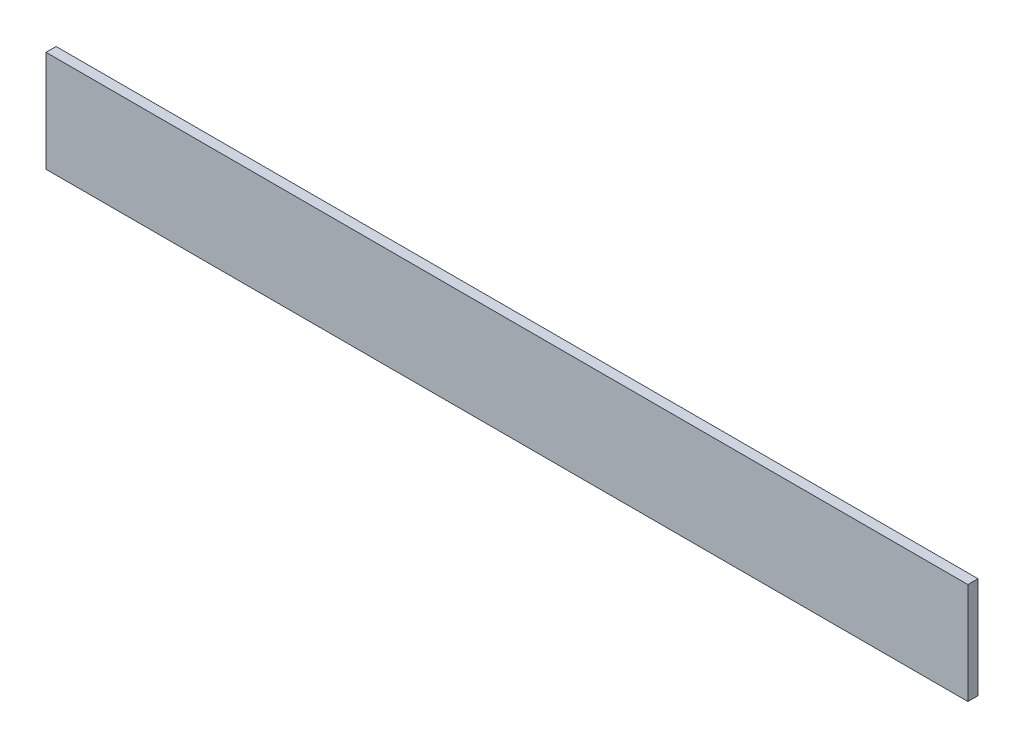
from build123d import *

# Parameters (mm, degrees)
ESQUISSE1_W        = 273
ESQUISSE1_H        = 30
BOSS_EXTRU_1_DEPTH = 3


with BuildPart() as part:
    # Esquisse1 → Boss.-Extru.1 (new body)
    with BuildSketch(Plane.XY):
        with Locations((-119.820766405, -4.529220779)):
            Rectangle(ESQUISSE1_W, ESQUISSE1_H)
    extrude(amount=BOSS_EXTRU_1_DEPTH)


solid = part.part
